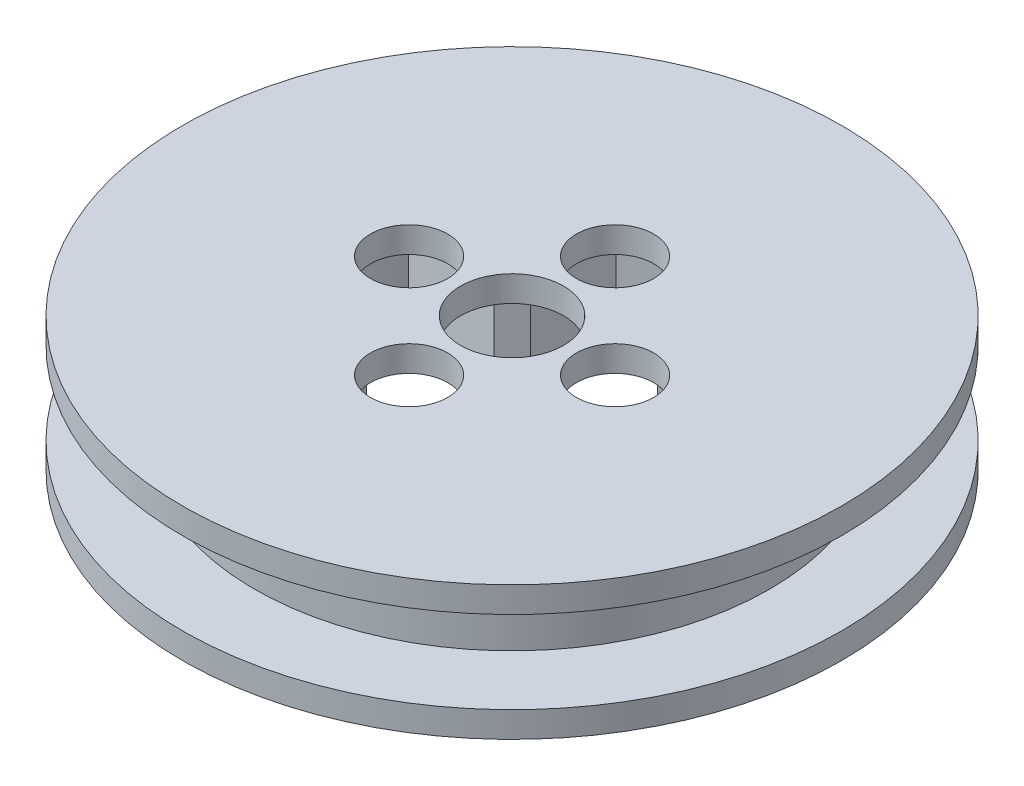
from build123d import *

# Parameters (mm, degrees)
SKETCH1_R           = 20.32
SKETCH1_R_2         = 3.175
SKETCH1_R_3         = 2.38125
BOSS_EXTRUDE1_DEPTH = 1.5875
SKETCH2_R           = 15.875
SKETCH2_R_2         = 13.589
BOSS_EXTRUDE2_DEPTH = 5.08
SKETCH3_R           = 20.32
SKETCH3_R_2         = 13.589
BOSS_EXTRUDE3_DEPTH = 1.5875
BOSS_EXTRUDE4_DEPTH = 6.6675


with BuildPart() as part:
    # Sketch1 → Boss-Extrude1 (new body)
    with BuildSketch(Plane.XZ.offset(4.640864108)):
        with Locations((64.802565284, 12.446906686)):
            Circle(SKETCH1_R)
        with Locations((64.802565284, 12.446906686)):
            Circle(SKETCH1_R_2, mode=Mode.SUBTRACT)
        with Locations((58.452565284, 12.446906686)):
            Circle(SKETCH1_R_3, mode=Mode.SUBTRACT)
        with Locations((71.152565284, 12.446906686)):
            Circle(SKETCH1_R_3, mode=Mode.SUBTRACT)
        with Locations((64.802565284, 18.796906686)):
            Circle(SKETCH1_R_3, mode=Mode.SUBTRACT)
        with Locations((64.802565284, 6.096906686)):
            Circle(SKETCH1_R_3, mode=Mode.SUBTRACT)
    extrude(amount=BOSS_EXTRUDE1_DEPTH)

    # Sketch2 → Boss-Extrude2 (add)
    with BuildSketch(Plane.XZ.offset(6.228364108)):
        with Locations((64.802565284, 12.446906686)):
            Circle(SKETCH2_R)
        with Locations((64.802565284, 12.446906686)):
            Circle(SKETCH2_R_2, mode=Mode.SUBTRACT)
    extrude(amount=BOSS_EXTRUDE2_DEPTH)

    # Sketch3 → Boss-Extrude3 (add)
    with BuildSketch(Plane.XZ.offset(11.308364108)):
        with Locations((64.802565284, 12.446906686)):
            Circle(SKETCH3_R)
        with Locations((64.802565284, 12.446906686)):
            Circle(SKETCH3_R_2, mode=Mode.SUBTRACT)
    extrude(amount=BOSS_EXTRUDE3_DEPTH)

    # Sketch4 → Boss-Extrude4 (add)
    with BuildSketch(Plane.XZ.offset(6.228364108)):
        with BuildLine():
            Line((52.542239657, 18.307396129), (59.751171216, 16.375768739))
            Line((59.751171216, 16.375768739), (60.873703231, 17.498300754))
            Line((60.873703231, 17.498300754), (58.942075841, 24.707232314))
            ThreePointArc((58.942075841, 24.707232314), (55.193691235, 22.055780736), (52.542239657, 18.307396129))
        make_face()
        with BuildLine():
            Line((70.663054727, 24.707232314), (68.731427337, 17.498300754))
            Line((68.731427337, 17.498300754), (69.853959352, 16.375768739))
            Line((69.853959352, 16.375768739), (77.062890912, 18.307396129))
            ThreePointArc((77.062890912, 18.307396129), (74.411439334, 22.055780736), (70.663054727, 24.707232314))
        make_face()
        with BuildLine():
            Line((77.062890912, 6.586417243), (69.853959352, 8.518044633))
            Line((69.853959352, 8.518044633), (68.731427337, 7.395512618))
            Line((68.731427337, 7.395512618), (70.663054727, 0.186581059))
            ThreePointArc((70.663054727, 0.186581059), (74.411439334, 2.838032636), (77.062890912, 6.586417243))
        make_face()
        with BuildLine():
            Line((58.942075841, 0.186581059), (60.873703231, 7.395512618))
            Line((60.873703231, 7.395512618), (59.751171216, 8.518044633))
            Line((59.751171216, 8.518044633), (52.542239657, 6.586417243))
            ThreePointArc((52.542239657, 6.586417243), (55.193691235, 2.838032636), (58.942075841, 0.186581059))
        make_face()
    extrude(amount=BOSS_EXTRUDE4_DEPTH)


solid = part.part
